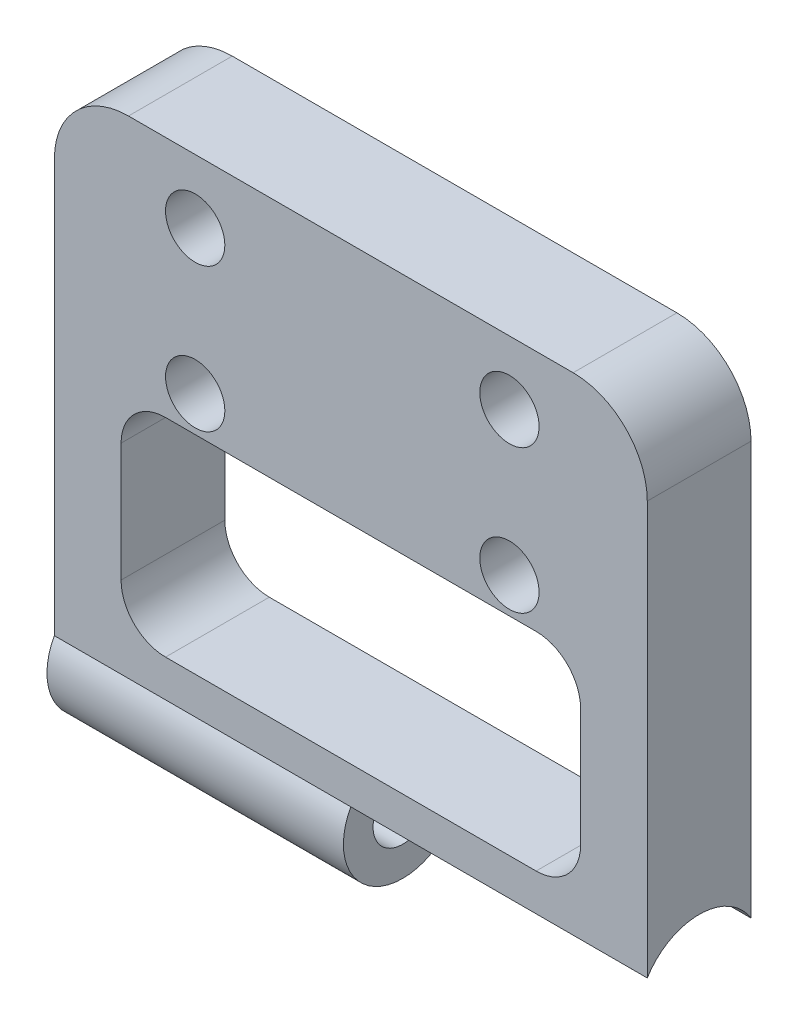
from build123d import *

# Parameters (mm, degrees)
SKETCH1_W                = 40
SKETCH1_H                = 35
BOSS_EXTRUDE1_DEPTH      = 7
SKETCH2_R                = 4.1
CUT_EXTRUDE1_DEPTH       = 20
SKETCH3_R                = 4
SKETCH3_R_2              = 2
BOSS_EXTRUDE2_DEPTH      = 11
BOSS_EXTRUDE2_DEPTH_BACK = 9
FILLET1_R                = 5
SKETCH4_R                = 2
SKETCH4_W                = 31
SKETCH4_H                = 14
CUT_EXTRUDE2_DEPTH       = 8.5
FILLET2_R                = 3
SKETCH5_R                = 2
CUT_EXTRUDE3_DEPTH       = 41


with BuildPart() as part:
    # Sketch1 → Boss-Extrude1 (new body)
    with BuildSketch(Plane.XY):
        with Locations((-2.229213179, -1.035620053)):
            Rectangle(SKETCH1_W, SKETCH1_H)
    extrude(amount=BOSS_EXTRUDE1_DEPTH)

    # Sketch2 → Cut-Extrude1 (cut)
    with BuildSketch(Plane(origin=(17.770786821, 0, 0), x_dir=(0, 0, -1), z_dir=(1, 0, 0))):
        with Locations((-3.5, -18.535620053)):
            Circle(SKETCH2_R)
    extrude(amount=-CUT_EXTRUDE1_DEPTH, mode=Mode.SUBTRACT)

    # Sketch3 → Boss-Extrude2 (add, two sides)
    with BuildSketch(Plane(origin=(-13.229213179, 0, 0), x_dir=(0, 0, -1), z_dir=(1, 0, 0))) as boss_extrude2_sk:
        with Locations((-3.5, -18.336696075)):
            Circle(SKETCH3_R)
        with Locations((-3.5, -18.336696075)):
            Circle(SKETCH3_R_2, mode=Mode.SUBTRACT)
    extrude(amount=BOSS_EXTRUDE2_DEPTH)
    extrude(boss_extrude2_sk.sketch, amount=-BOSS_EXTRUDE2_DEPTH_BACK)

    # Fillet1
    fillet1_edges = [part.edges().sort_by_distance(p)[0] for p in [
        (-22.229213179, 16.464379947, 3.5),
        (17.770786821, 16.464379947, 3.5),
    ]]
    fillet(fillet1_edges, radius=FILLET1_R)

    # Sketch4 → Cut-Extrude2 (cut, through all)
    with BuildSketch(Plane(origin=(0, 0, 0), x_dir=(-1, 0, 0), z_dir=(0, 0, -1))):
        with Locations((-8.470786821, 12.164379947)):
            Circle(SKETCH4_R)
        with Locations((12.729213179, 12.164379947)):
            Circle(SKETCH4_R)
        with Locations((12.729213179, 2.489379947)):
            Circle(SKETCH4_R)
        with Locations((-8.470786821, 2.489379947)):
            Circle(SKETCH4_R)
        with Locations((2.229213179, -6.900204402)):
            Rectangle(SKETCH4_W, SKETCH4_H)
    extrude(amount=-CUT_EXTRUDE2_DEPTH, mode=Mode.SUBTRACT)

    # Fillet2
    fillet2_edges = [part.edges().sort_by_distance(p)[0] for p in [
        (-17.729213179, 0.099795598, 3.5),
        (-17.729213179, -13.900204402, 3.5),
        (13.270786821, -13.900204402, 3.5),
        (13.270786821, 0.099795598, 3.5),
    ]]
    fillet(fillet2_edges, radius=FILLET2_R)

    # Sketch5 → Cut-Extrude3 (cut, through all)
    with BuildSketch(Plane.ZY.offset(22.229213179)):
        with Locations((3.5, -18.336696075)):
            Circle(SKETCH5_R)
    extrude(amount=-CUT_EXTRUDE3_DEPTH, mode=Mode.SUBTRACT)


solid = part.part
